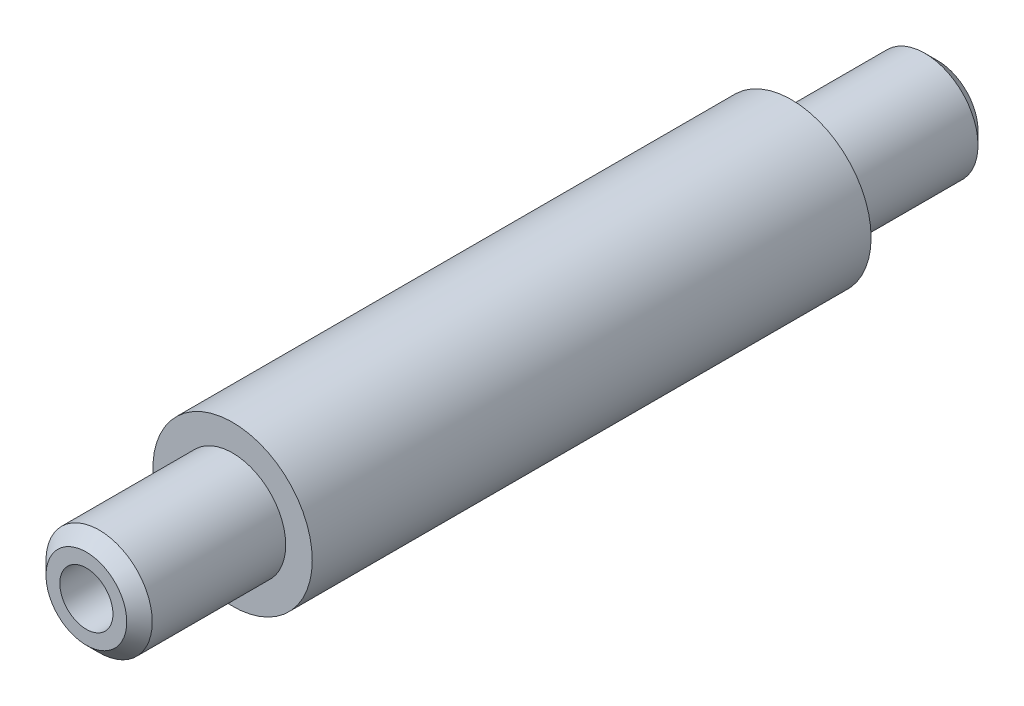
from build123d import *


with BuildPart() as part:
    # Sketch1 → Revolve1 (revolve)
    with BuildSketch(Plane(origin=(0, 0, 0), x_dir=(0, 0, -1), z_dir=(1, 0, 0))):
        Polygon((-0.1524, 3.175), (101.6, 3.175), (101.6, 4.826), (100.076, 6.35), (84.1248, 6.35), (84.1248, 9.525), (17.3228, 9.525), (17.3228, 6.35), (1.3716, 6.35), (-0.1524, 4.826), align=None)
    revolve(axis=Axis((0, 0, 0), (0, 0, -1)))


solid = part.part
